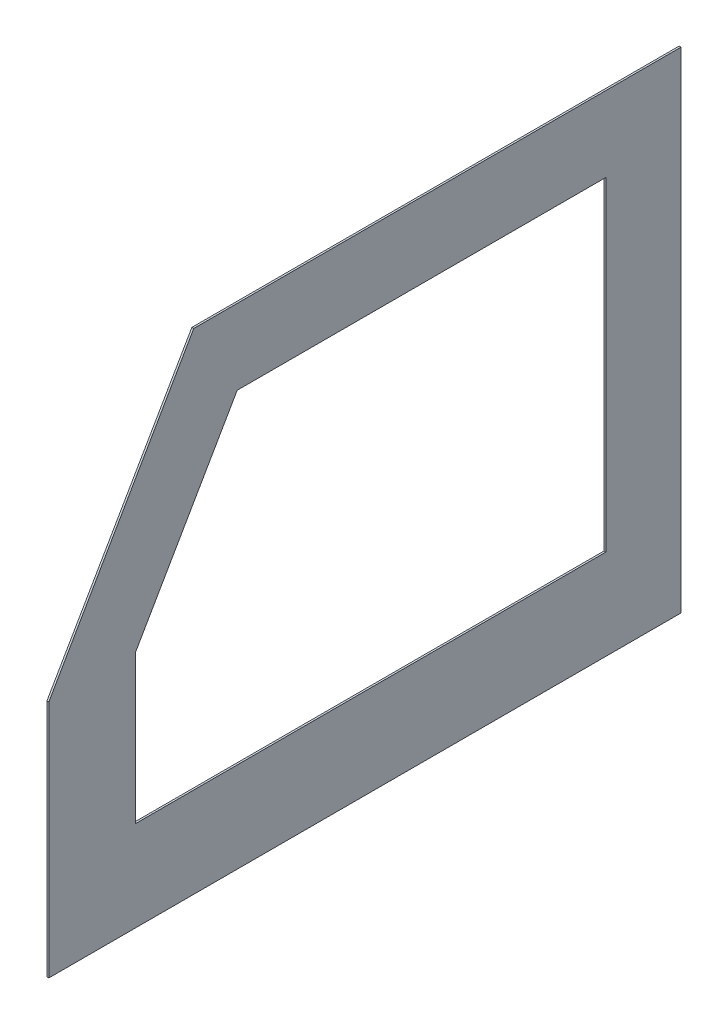
from build123d import *

# Parameters (mm, degrees)
BOSS_EXTRUDE1_DEPTH = 3.175
CUT_EXTRUDE1_REACH  = 5.175


with BuildPart() as part:
    # Sketch1 → Boss-Extrude1 (new body)
    with BuildSketch(Plane(origin=(0, 0, 0), x_dir=(0, 0, -1), z_dir=(1, 0, 0))):
        Polygon((0, 0), (-822.266180236, 0), (-1066.8, -423.545), (-1066.8, -826.77), (0, -826.77), align=None)
    extrude(amount=BOSS_EXTRUDE1_DEPTH)

    # Sketch2 → Cut-Extrude1 (cut, up to next)
    with BuildSketch(Plane(origin=(3.175, 0, 0), x_dir=(0, 0, -1), z_dir=(1, 0, 0)), mode=Mode.PRIVATE) as cut_extrude1_sk1:
        Polygon((-748.942696049, -127), (-920.153031626, -423.545), (-920.153031626, -674.37), (-127, -674.37), (-127, -423.545), (-127, -127), align=None)
    cut_extrude1_tool1 = extrude(cut_extrude1_sk1.sketch, amount=-CUT_EXTRUDE1_REACH, mode=Mode.PRIVATE) & part.part
    add(cut_extrude1_tool1.solids().sort_by_distance((3.175, -411.543058, 502.491806))[0], mode=Mode.SUBTRACT)


solid = part.part
